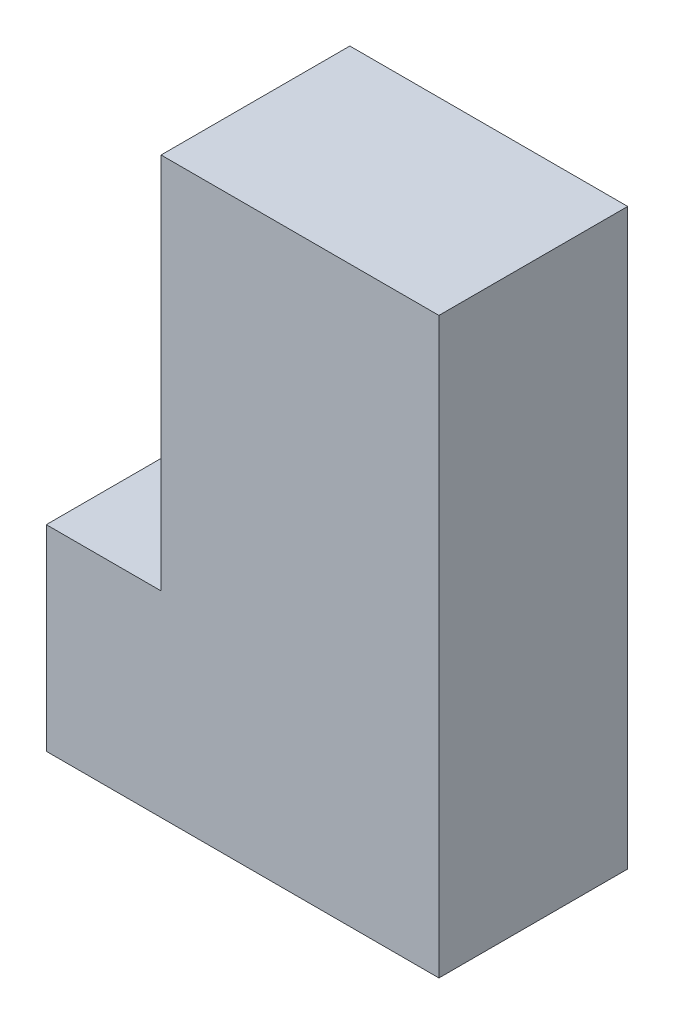
from build123d import *

# Parameters (mm, degrees)
BOSS_EXTRUDE1_DEPTH = 12.5


with BuildPart() as part:
    # Sketch1 → Boss-Extrude1 (new body)
    with BuildSketch(Plane.XY):
        Polygon((0, 0), (26, 0), (26, 38), (7.6, 38), (7.6, 13), (0, 13), align=None)
    extrude(amount=BOSS_EXTRUDE1_DEPTH)


solid = part.part
